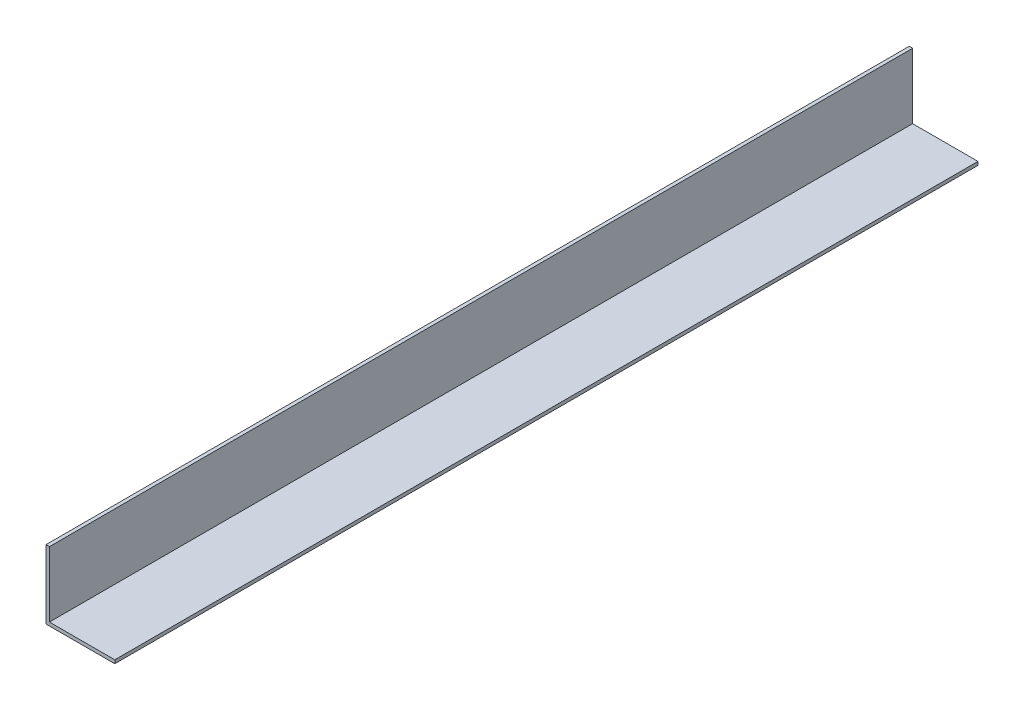
from build123d import *

# Parameters (mm, degrees)
EXTRUDE_1_DEPTH = 251


with BuildPart() as part:
    # Эскиз1 → Бобышка-Вытянуть1 (new body)
    with BuildSketch(Plane.XY):
        Polygon((0, 0), (0, 20), (1, 20), (1, 1), (20, 1), (20, 0), align=None)
    extrude(amount=EXTRUDE_1_DEPTH)


solid = part.part
